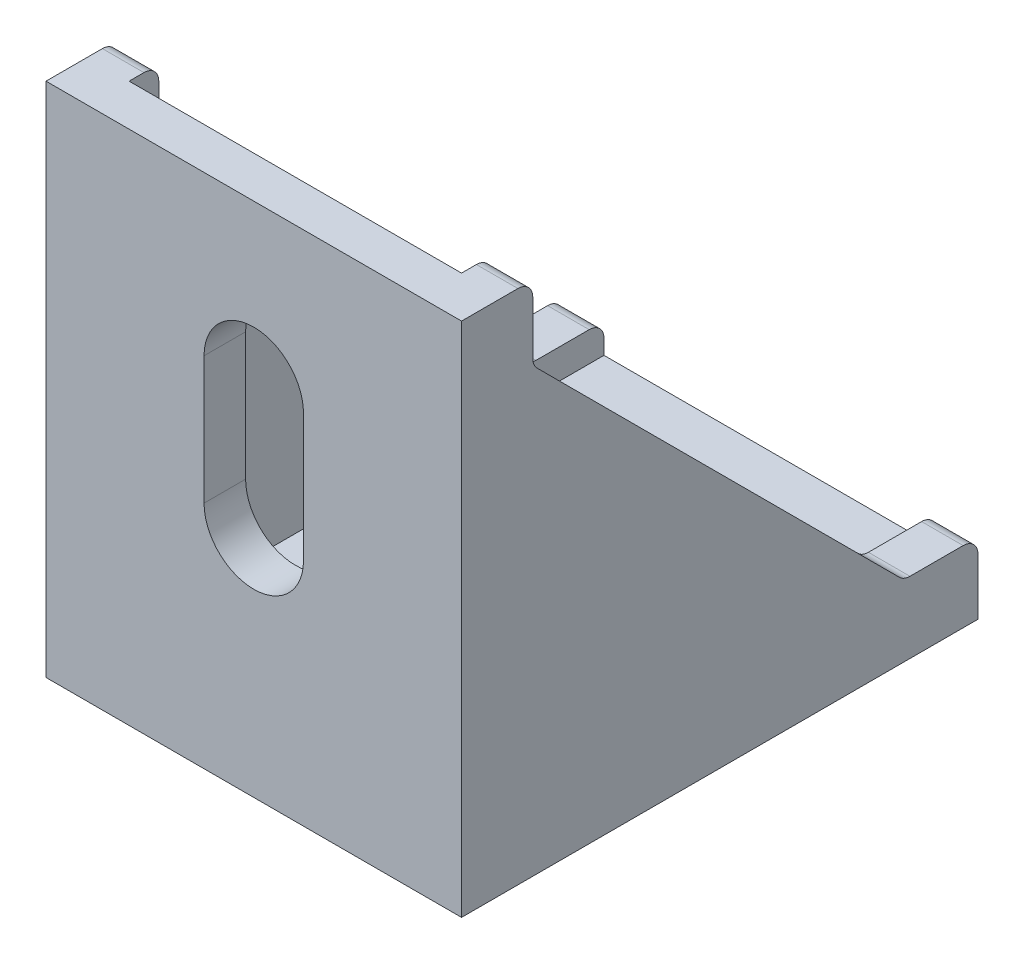
from build123d import *

# Parameters (mm, degrees)
EXTRUDE_1_DEPTH     = 14
EXTRUDE_3_DEPTH     = 2.8
FILLET_1_R          = 1
CUT_EXTRUDE_1_DEPTH = 2.8
CUT_EXTRUDE_2_DEPTH = 2.8


with BuildPart() as part:
    # 草图1 → 凸台-拉伸1 (new body, symmetric)
    with BuildSketch(Plane(origin=(0, 0, 0), x_dir=(0, 0, -1), z_dir=(1, 0, 0))):
        Polygon((0, 34.8), (0, 0), (34.8, 0), (34.8, 2.8), (2.8, 2.8), (2.8, 34.8), align=None)
    extrude(amount=EXTRUDE_1_DEPTH, both=True)

    # 草图2 → 凸台-拉伸3 (add)
    with BuildSketch(Plane(origin=(14, 0, 0), x_dir=(0, 0, -1), z_dir=(1, 0, 0))):
        Polygon((2.8, 34.8), (4.8, 34.8), (4.8, 29.8), (29.8, 4.8), (34.8, 4.8), (34.8, 2.8), (2.8, 2.8), align=None)
    extrude_3 = extrude(amount=-EXTRUDE_3_DEPTH)

    # 镜向1: 凸台-拉伸3 across plane
    add(extrude_3.mirror(Plane(origin=(0, 0, 0), x_dir=(0, 0, 1), z_dir=(1, 0, 0))))

    # 圆角1
    fillet_1_edges = [part.edges().sort_by_distance(p)[0] for p in [
        (12.6, 34.8, -4.8),
        (12.6, 29.8, -4.8),
        (12.6, 4.8, -29.8),
        (12.6, 4.8, -34.8),
        (-12.6, 4.8, -34.8),
        (-12.6, 4.8, -29.8),
        (-12.6, 29.8, -4.8),
        (-12.6, 34.8, -4.8),
    ]]
    fillet(fillet_1_edges, radius=FILLET_1_R)

    # 草图3 → 切除-拉伸1 (cut)
    with BuildSketch(Plane(origin=(0, 2.8, 0), x_dir=(1, 0, 0), z_dir=(0, 1, 0))):
        with BuildLine():
            Line((-3.35, 15.5), (-3.35, 24.1))
            ThreePointArc((-3.35, 24.1), (0, 27.45), (3.35, 24.1))
            Line((3.35, 24.1), (3.35, 15.5))
            ThreePointArc((3.35, 15.5), (0, 12.15), (-3.35, 15.5))
        make_face()
    extrude(amount=-CUT_EXTRUDE_1_DEPTH, mode=Mode.SUBTRACT)

    # 草图4 → 切除-拉伸2 (cut)
    with BuildSketch(Plane(origin=(0, 0, -2.8), x_dir=(-1, 0, 0), z_dir=(0, 0, -1))):
        with BuildLine():
            Line((-3.35, 15.5), (-3.35, 24.1))
            ThreePointArc((-3.35, 24.1), (0, 27.45), (3.35, 24.1))
            Line((3.35, 24.1), (3.35, 15.5))
            ThreePointArc((3.35, 15.5), (0, 12.15), (-3.35, 15.5))
        make_face()
    extrude(amount=-CUT_EXTRUDE_2_DEPTH, mode=Mode.SUBTRACT)


solid = part.part
